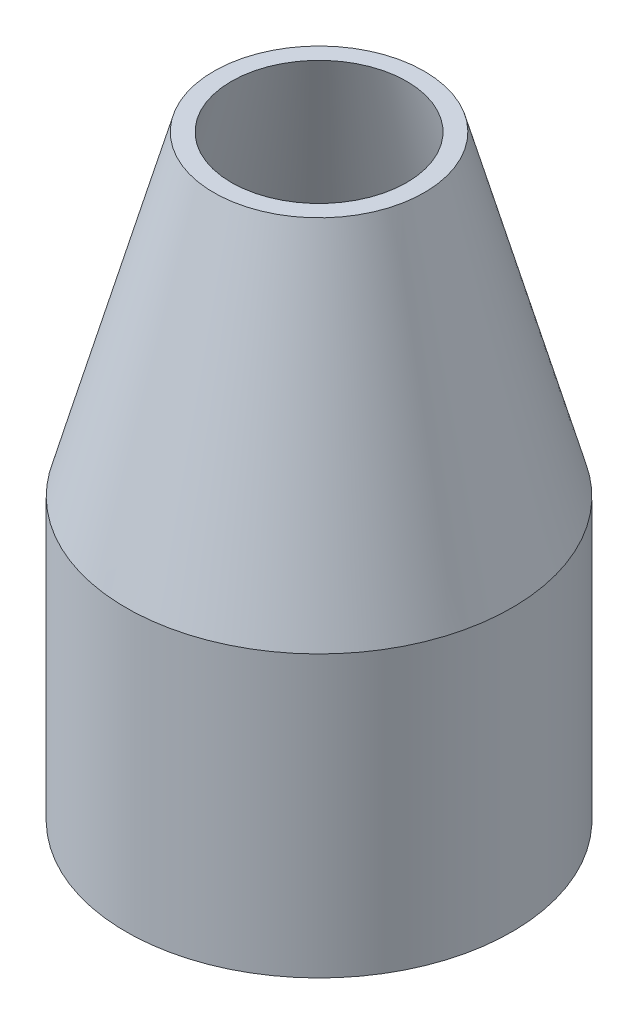
from build123d import *


with BuildPart() as part:
    # Sketch1 → Revolve2 (revolve)
    with BuildSketch(Plane.XY):
        Polygon((5.5, 0), (5.5, 8), (3, 17), (2.5, 17), (5, 8), (5, 0), align=None)
    revolve(axis=Axis((0, 0, 0), (0, 1, 0)))


solid = part.part
